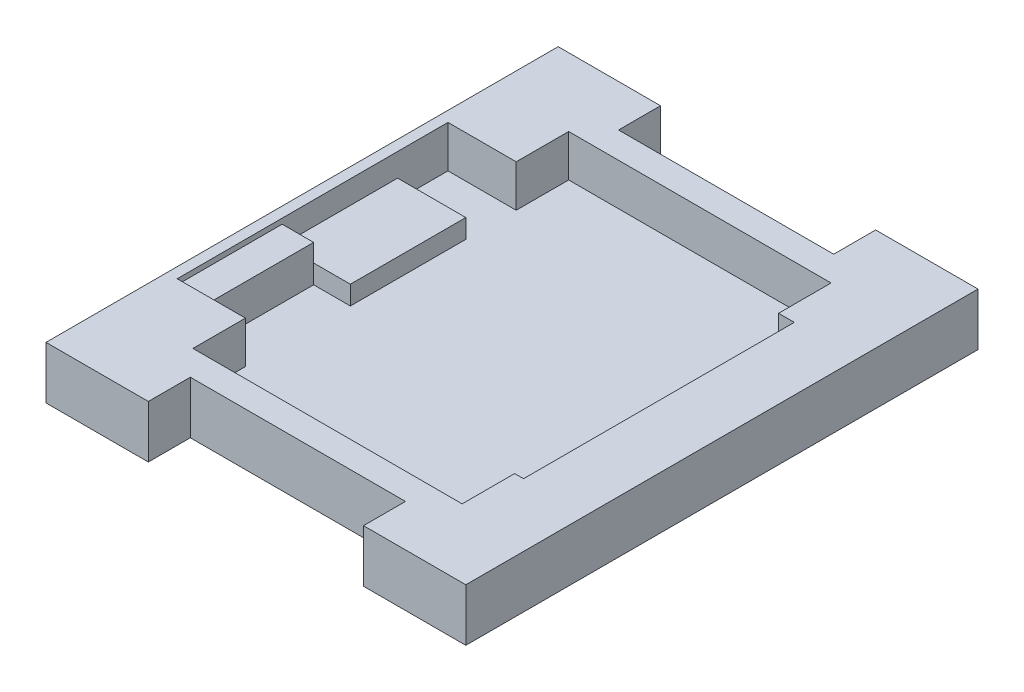
from build123d import *

# Parameters (mm, degrees)
SKETCH1_W           = 40
SKETCH1_H           = 48.8
BOSS_EXTRUDE1_DEPTH = 1
SKETCH2_W           = 40
SKETCH2_H           = 48.8
SKETCH2_W_2         = 38
SKETCH2_H_2         = 35.8
BOSS_EXTRUDE2_DEPTH = 4
SKETCH3_W           = 20.5
SKETCH3_H           = 8
CUT_EXTRUDE1_DEPTH  = 6
BOSS_EXTRUDE3_REACH = 7
SKETCH4_W           = 6.5
SKETCH4_H           = 5
SKETCH5_W           = 7
SKETCH5_H           = 11
BOSS_EXTRUDE4_DEPTH = 2.8
SKETCH7_W           = 10
SKETCH7_H           = 4.5
BOSS_EXTRUDE5_DEPTH = 4


with BuildPart() as part:
    # Sketch1 → Boss-Extrude1 (new body)
    with BuildSketch(Plane(origin=(0, 0, 0), x_dir=(1, 0, 0), z_dir=(0, 1, 0))):
        Rectangle(SKETCH1_W, SKETCH1_H)
    extrude(amount=BOSS_EXTRUDE1_DEPTH)

    # Sketch2 → Boss-Extrude2 (add)
    with BuildSketch(Plane(origin=(0, 1, 0), x_dir=(1, 0, 0), z_dir=(0, 1, 0))):
        Rectangle(SKETCH2_W, SKETCH2_H)
        Rectangle(SKETCH2_W_2, SKETCH2_H_2, mode=Mode.SUBTRACT)
    extrude(amount=BOSS_EXTRUDE2_DEPTH)

    # Sketch3 → Cut-Extrude1 (cut, through all)
    with BuildSketch(Plane(origin=(0, 5, 0), x_dir=(1, 0, 0), z_dir=(0, 1, 0))):
        with Locations((0, -24.4)):
            Rectangle(SKETCH3_W, SKETCH3_H)
        with Locations((0, 24.4)):
            Rectangle(SKETCH3_W, SKETCH3_H)
    extrude(amount=-CUT_EXTRUDE1_DEPTH, mode=Mode.SUBTRACT)

    # Sketch4 → Boss-Extrude3 (add, up to next)
    with BuildSketch(Plane(origin=(0, 5, 0), x_dir=(1, 0, 0), z_dir=(0, 1, 0)), mode=Mode.PRIVATE) as boss_extrude3_sk1:
        with Locations((-15.75, -15.4)):
            Rectangle(SKETCH4_W, SKETCH4_H)
    boss_extrude3_tool1 = extrude(boss_extrude3_sk1.sketch, amount=-BOSS_EXTRUDE3_REACH, mode=Mode.PRIVATE) - part.part
    add(boss_extrude3_tool1.solids().sort_by_distance((-15.75, 5, 15.4))[0])
    # Sketch4 → Boss-Extrude3 (add, up to next)
    with BuildSketch(Plane(origin=(0, 5, 0), x_dir=(1, 0, 0), z_dir=(0, 1, 0)), mode=Mode.PRIVATE) as boss_extrude3_sk2:
        with Locations((-15.75, 15.4)):
            Rectangle(SKETCH4_W, SKETCH4_H)
    boss_extrude3_tool2 = extrude(boss_extrude3_sk2.sketch, amount=-BOSS_EXTRUDE3_REACH, mode=Mode.PRIVATE) - part.part
    add(boss_extrude3_tool2.solids().sort_by_distance((-15.75, 5, -15.4))[0])
    # Sketch4 → Boss-Extrude3 (add, up to next)
    with BuildSketch(Plane(origin=(0, 5, 0), x_dir=(1, 0, 0), z_dir=(0, 1, 0)), mode=Mode.PRIVATE) as boss_extrude3_sk3:
        Polygon((19, 17.9), (19, -17.9), (13.150842714, -17.9), (13.150842714, -12.9), (14, -12.9), (14, 12.9), (12.5, 12.9), (12.5, 17.9), align=None)
    boss_extrude3_tool3 = extrude(boss_extrude3_sk3.sketch, amount=-BOSS_EXTRUDE3_REACH, mode=Mode.PRIVATE) - part.part
    add(boss_extrude3_tool3.solids().sort_by_distance((16.307114, 5, -0.262731))[0])

    # Sketch5 → Boss-Extrude4 (add)
    with BuildSketch(Plane.XZ):
        with Locations((-16, -2.6)):
            Rectangle(SKETCH5_W, SKETCH5_H)
    extrude(amount=-BOSS_EXTRUDE4_DEPTH)

    # Sketch7 → Boss-Extrude5 (add)
    with BuildSketch(Plane.ZY.offset(20)):
        with Locations((7.9, 2.25)):
            Rectangle(SKETCH7_W, SKETCH7_H)
    extrude(amount=-BOSS_EXTRUDE5_DEPTH)


solid = part.part
